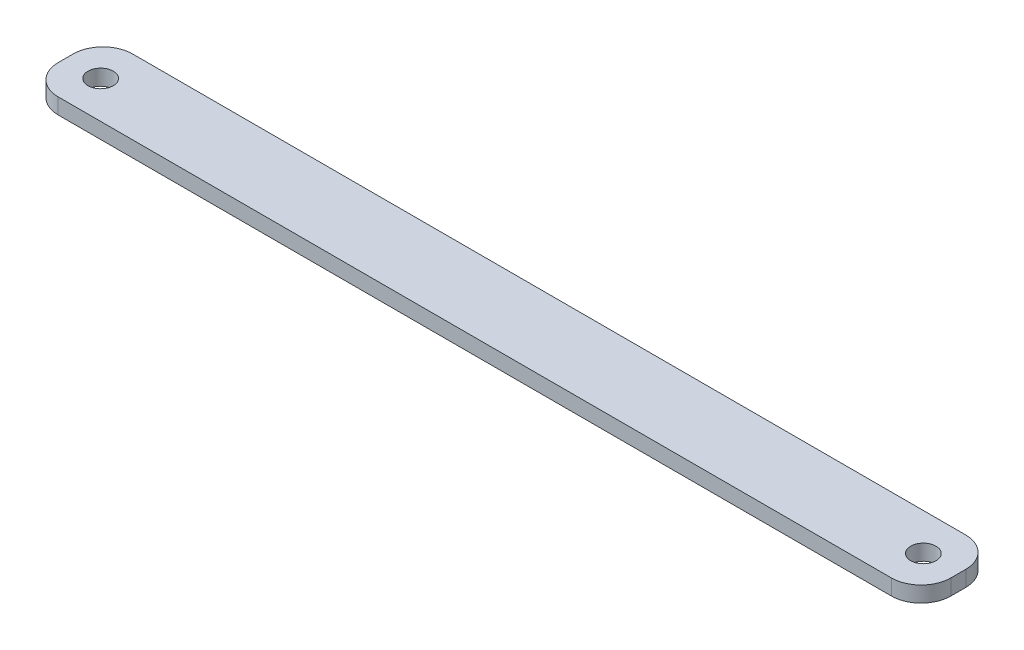
from build123d import *

# Parameters (mm, degrees)
CROQUIS1_W              = 120
CROQUIS1_H              = 10
CROQUIS1_R              = 1.7
SALIENTE_EXTRUIR1_DEPTH = 2.11
REDONDEO1_R             = 4


with BuildPart() as part:
    # Croquis1 → Saliente-Extruir1 (new body)
    with BuildSketch(Plane(origin=(0, 0, 0), x_dir=(1, 0, 0), z_dir=(0, 1, 0))):
        Rectangle(CROQUIS1_W, CROQUIS1_H)
        with Locations((-55.3, 0)):
            Circle(CROQUIS1_R, mode=Mode.SUBTRACT)
        with Locations((55.3, 0)):
            Circle(CROQUIS1_R, mode=Mode.SUBTRACT)
    extrude(amount=SALIENTE_EXTRUIR1_DEPTH)

    # Redondeo1
    redondeo1_edges = [part.edges().sort_by_distance(p)[0] for p in [
        (60, 1.055, 5),
        (-60, 1.055, 5),
        (-60, 1.055, -5),
        (60, 1.055, -5),
    ]]
    fillet(redondeo1_edges, radius=REDONDEO1_R)


solid = part.part
